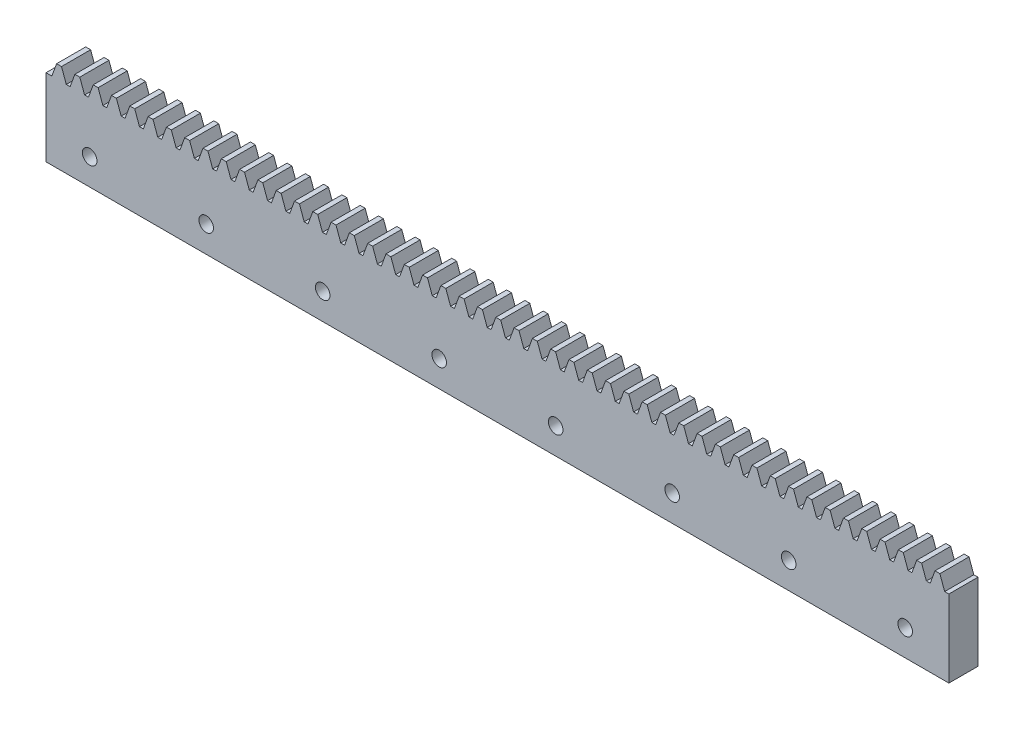
from build123d import *

# Parameters (mm, degrees)
SKETCH_1_W             = 155
SKETCH_1_H             = 9
EXTRUDE_1_DEPTH        = 5
SKETCH_3_W             = 155
SKETCH_3_H             = 5
EXTRUDE_2_DEPTH        = 4.25
EXTRUDE_3_DEPTH        = 5
M3X0_5_1_D             = 2.5
PATTERN_LINEAR_1_COUNT = 49
PATTERN_LINEAR_1_PITCH = 3.141592654
PATTERN_LINEAR_2_COUNT = 8
PATTERN_LINEAR_2_PITCH = 20


with BuildPart() as part:
    # 草圖1 → 填料-伸長1 (new body)
    with BuildSketch(Plane.XY):
        Rectangle(SKETCH_1_W, SKETCH_1_H)
    extrude(amount=EXTRUDE_1_DEPTH)

    # 草圖3 → 填料-伸長2 (add)
    with BuildSketch(Plane(origin=(0, 4.5, 0), x_dir=(1, 0, 0), z_dir=(0, 1, 0))):
        with Locations((0, -2.5)):
            Rectangle(SKETCH_3_W, SKETCH_3_H)
    extrude(amount=EXTRUDE_2_DEPTH)

    # 草圖4 → 填料-伸長3 (add, through all)
    with BuildSketch(Plane.XY):
        Polygon((-76.5, 8.75), (-74.019278088, 8.75), (-74.838211115, 11), (-75.681066973, 11), align=None)
    extrude_3 = extrude(amount=EXTRUDE_3_DEPTH)

    # M3x0.5 螺紋孔1 (through all)
    with Locations(Plane.XY.offset(5)):
        with Locations((-70, 0)):
            m3x0_5_1 = Hole(M3X0_5_1_D / 2)

    # 直線複製排列1: 填料-伸長3 ×49
    with Locations(*[(i * PATTERN_LINEAR_1_PITCH, 0, 0) for i in range(1, PATTERN_LINEAR_1_COUNT)]):
        add(extrude_3)

    # 直線複製排列2: M3x0.5 螺紋孔1 ×8
    with Locations(*[(i * PATTERN_LINEAR_2_PITCH, 0, 0) for i in range(1, PATTERN_LINEAR_2_COUNT)]):
        add(m3x0_5_1, mode=Mode.SUBTRACT)


solid = part.part
